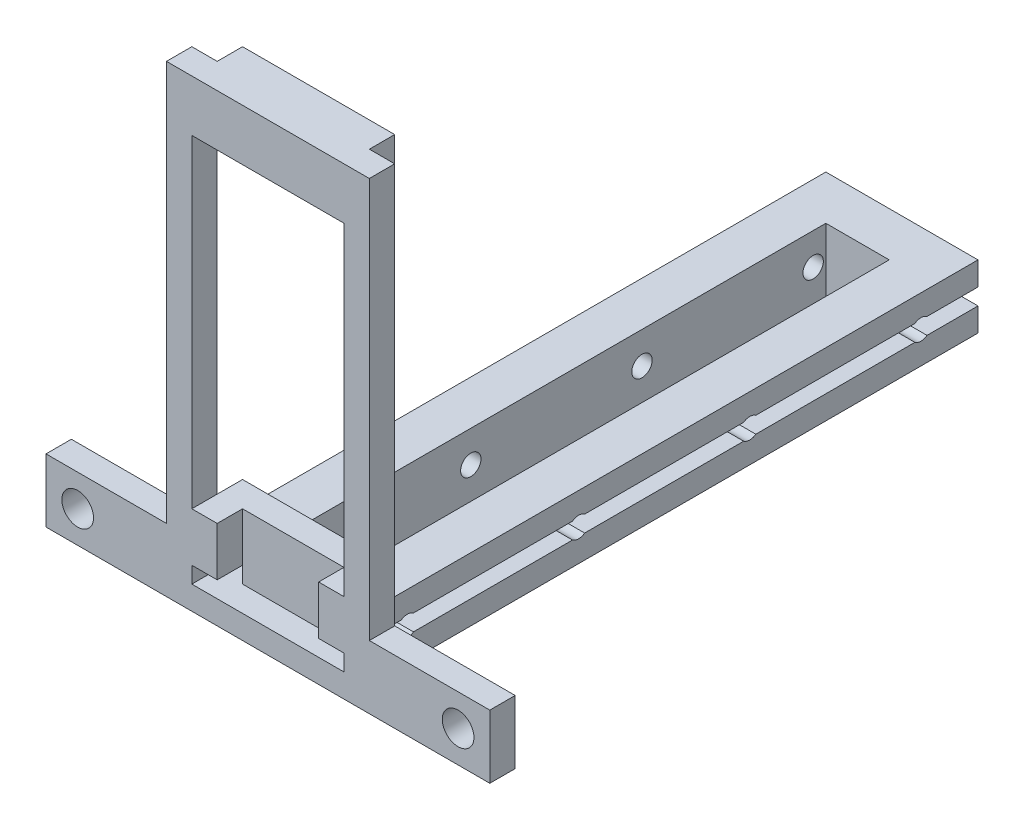
from build123d import *

# Parameters (mm, degrees)
SKETCH1_W                     = 88.9
SKETCH1_H                     = 12.7
SMALL_BASE_EXTRUDE_DEPTH      = 5.08
SKETCH3_W                     = 30.48
SKETCH3_H                     = 12.7
MAIN_TOWER_EXTRUDE_DEPTH      = 121.92
SKETCH4_W                     = 12.7
SKETCH4_H                     = 107.95
FILAMENT_CHANNEL_CUT_DEPTH    = 13.7
SKETCH6_R                     = 2.03962
CUT_EXTRUDE3_DEPTH            = 8.89
LPATTERN1_COUNT               = 4
LPATTERN1_PITCH               = 34.29
SKETCH9_R                     = 2.03962
CUT_EXTRUDE6_DEPTH            = 8.89
LPATTERN2_COUNT               = 4
LPATTERN2_PITCH               = 34.29
SKETCH10_W                    = 5.08
SKETCH10_H                    = 3.2766
WIRE_CHANNEL_CUT_DEPTH        = 228.6
SKETCH11_R                    = 3.175
MOUNTING_BOLT_HOLE_CUTS_DEPTH = 25.4
COPPER_BOARD_EXTRUDE_DEPTH    = 80.16
SKETCH13_W                    = 30.48
SKETCH13_H                    = 64.772627344
COPPER_BOARD_CUT_DEPTH        = 10.16
WIRE_ESCAPE_HOLE_CUT_DEPTH    = 5.08


with BuildPart() as part:
    # Sketch1 → Small Base Extrude (new body)
    with BuildSketch(Plane(origin=(0, 0, 0), x_dir=(1, 0, 0), z_dir=(0, 0, -1))):
        with Locations((0, -6.35)):
            Rectangle(SKETCH1_W, SKETCH1_H)
    extrude(amount=SMALL_BASE_EXTRUDE_DEPTH)

    # Sketch3 → Main Tower Extrude (add)
    with BuildSketch(Plane(origin=(0, 0, -5.08), x_dir=(1, 0, 0), z_dir=(0, 0, -1))):
        with Locations((0, -6.35)):
            Rectangle(SKETCH3_W, SKETCH3_H)
    extrude(amount=MAIN_TOWER_EXTRUDE_DEPTH)

    # Sketch4 → Filament Channel Cut (cut, through all)
    with BuildSketch(Plane(origin=(0, 12.7, 0), x_dir=(1, 0, 0), z_dir=(0, 1, 0))):
        with Locations((0, 64.135)):
            Rectangle(SKETCH4_W, SKETCH4_H)
    extrude(amount=-FILAMENT_CHANNEL_CUT_DEPTH, mode=Mode.SUBTRACT)

    # Sketch6 → Cut-Extrude3 (cut)
    with BuildSketch(Plane(origin=(-6.35, 0, 0), x_dir=(0, 0, -1), z_dir=(1, 0, 0))):
        with Locations((12.7, 6.35)):
            Circle(SKETCH6_R)
    cut_extrude3 = extrude(amount=-CUT_EXTRUDE3_DEPTH, mode=Mode.SUBTRACT)

    # LPattern1: Cut-Extrude3 ×4
    with Locations(*[(0, 0, -i * LPATTERN1_PITCH) for i in range(1, LPATTERN1_COUNT)]):
        add(cut_extrude3, mode=Mode.SUBTRACT)

    # Sketch9 → Cut-Extrude6 (cut)
    with BuildSketch(Plane(origin=(6.35, 57.001874069, -16.025022356), x_dir=(0, 0, 1), z_dir=(-1, 0, 0))):
        with Locations((3.325022356, -50.651874069)):
            Circle(SKETCH9_R)
    cut_extrude6 = extrude(amount=-CUT_EXTRUDE6_DEPTH, mode=Mode.SUBTRACT)

    # LPattern2: Cut-Extrude6 ×4
    with Locations(*[(0, 0, -i * LPATTERN2_PITCH) for i in range(1, LPATTERN2_COUNT)]):
        add(cut_extrude6, mode=Mode.SUBTRACT)

    # Sketch10 → Wire Channel Cut (cut)
    with BuildSketch(Plane(origin=(0, 0, -127), x_dir=(-1, 0, 0), z_dir=(0, 0, -1))):
        with Locations((12.7, 6.35)):
            Rectangle(SKETCH10_W, SKETCH10_H)
        with Locations((-12.7, 6.35)):
            Rectangle(SKETCH10_W, SKETCH10_H)
    extrude(amount=-WIRE_CHANNEL_CUT_DEPTH, mode=Mode.SUBTRACT)

    # Sketch11 → Mounting Bolt Hole Cuts (cut)
    with BuildSketch(Plane.XY):
        with Locations((38.1, 6.35)):
            Circle(SKETCH11_R)
        with Locations((-38.1, 6.35)):
            Circle(SKETCH11_R)
    extrude(amount=-MOUNTING_BOLT_HOLE_CUTS_DEPTH, mode=Mode.SUBTRACT)

    # Sketch12 → Copper Board Extrude (add)
    with BuildSketch(Plane(origin=(0, 12.7, 0), x_dir=(1, 0, 0), z_dir=(0, 1, 0))):
        Polygon((-15.24, 0), (15.24, 0), (20.32, 0), (20.32, 5.08), (15.24, 5.08), (15.24, 10.16), (-15.24, 10.16), (-15.24, 5.08), (-20.32, 5.08), (-20.32, 0), align=None)
    extrude(amount=COPPER_BOARD_EXTRUDE_DEPTH)

    # Sketch13 → Copper Board Cut (cut)
    with BuildSketch(Plane(origin=(0, 0, -10.16), x_dir=(-1, 0, 0), z_dir=(0, 0, -1))):
        with Locations((0, 50.166313672)):
            Rectangle(SKETCH13_W, SKETCH13_H)
    extrude(amount=-COPPER_BOARD_CUT_DEPTH, mode=Mode.SUBTRACT)

    # Sketch14 → Wire Escape Hole Cut (cut)
    with BuildSketch(Plane.XY):
        Polygon((-10.16, 4.7117), (10.16, 4.7117), (10.16, 7.9883), (10.16, 17.78), (-10.16, 17.78), (-10.16, 6.0833), align=None)
    extrude(amount=-WIRE_ESCAPE_HOLE_CUT_DEPTH, mode=Mode.SUBTRACT)


solid = part.part
